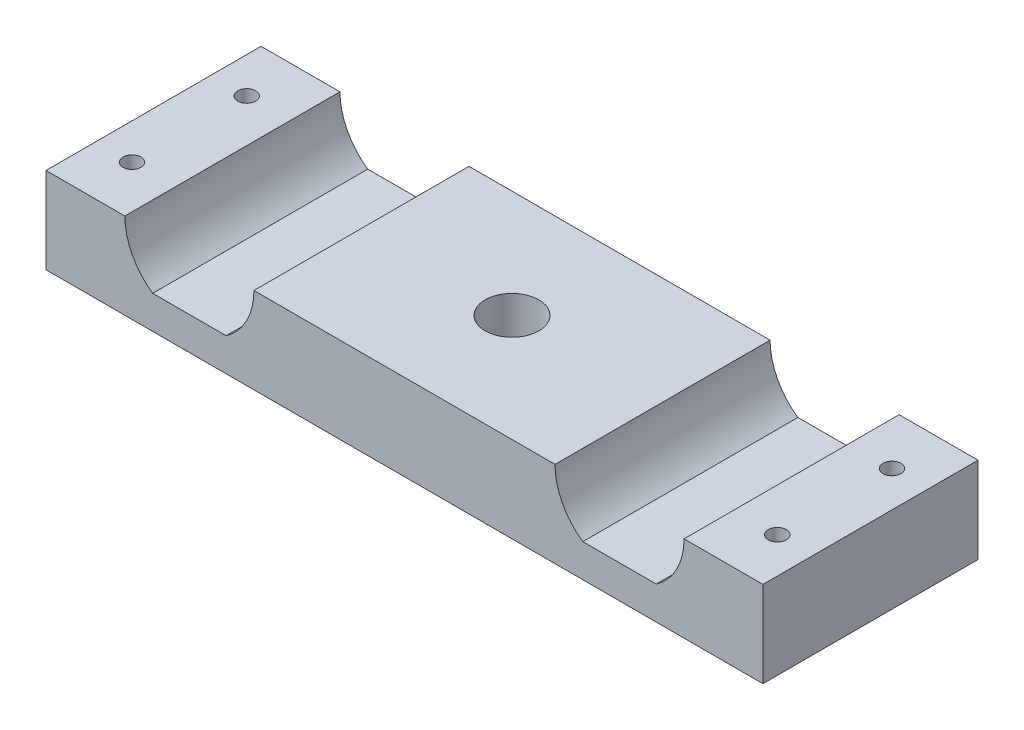
from build123d import *

# Parameters (mm, degrees)
BOSS_EXTRUDE1_DEPTH  = 38.1
HOLE1_D              = 9.525
HOLE1_DEPTH          = 101.6
HOLE2_D              = 3.175
HOLE2_DEPTH          = 101.6
LPATTERN1_COUNT      = 2
LPATTERN1_PITCH      = 20.32
LPATTERN1_COUNT_DIR2 = 2
LPATTERN1_PITCH_DIR2 = 114.3


with BuildPart() as part:
    # Sketch1 → Boss-Extrude1 (new body)
    with BuildSketch(Plane.XY):
        with BuildLine():
            Line((-63.5, 0), (63.5, 0))
            Line((63.5, 0), (63.5, 15.24))
            Line((63.5, 15.24), (49.53, 15.24))
            ThreePointArc((49.53, 15.24), (48.224317592, 9.934993562), (44.605574225, 5.842))
            Line((44.605574225, 5.842), (31.594425775, 5.842))
            ThreePointArc((31.594425775, 5.842), (27.975682408, 9.934993562), (26.67, 15.24))
            Line((26.67, 15.24), (-26.67, 15.24))
            ThreePointArc((-26.67, 15.24), (-27.975682408, 9.934993562), (-31.594425775, 5.842))
            Line((-31.594425775, 5.842), (-44.605574225, 5.842))
            ThreePointArc((-44.605574225, 5.842), (-48.224317592, 9.934993562), (-49.53, 15.24))
            Line((-49.53, 15.24), (-63.5, 15.24))
            Line((-63.5, 15.24), (-63.5, 0))
        make_face()
    extrude(amount=BOSS_EXTRUDE1_DEPTH)

    # Hole1
    with Locations(Plane(origin=(0, 15.24, 0), x_dir=(1, 0, 0), z_dir=(0, 1, 0))):
        with Locations((0, -19.05)):
            Hole(HOLE1_D / 2, depth=HOLE1_DEPTH)

    # Hole2
    with Locations(Plane(origin=(0, 15.24, 0), x_dir=(1, 0, 0), z_dir=(0, 1, 0))):
        with Locations((-57.15, -8.89)):
            hole2 = Hole(HOLE2_D / 2, depth=HOLE2_DEPTH)

    # LPattern1: Hole2 2 × 2
    with Locations(*[(j * LPATTERN1_PITCH_DIR2, 0, i * LPATTERN1_PITCH) for i in range(LPATTERN1_COUNT) for j in range(LPATTERN1_COUNT_DIR2) if (i, j) != (0, 0)]):
        add(hole2, mode=Mode.SUBTRACT)


solid = part.part
